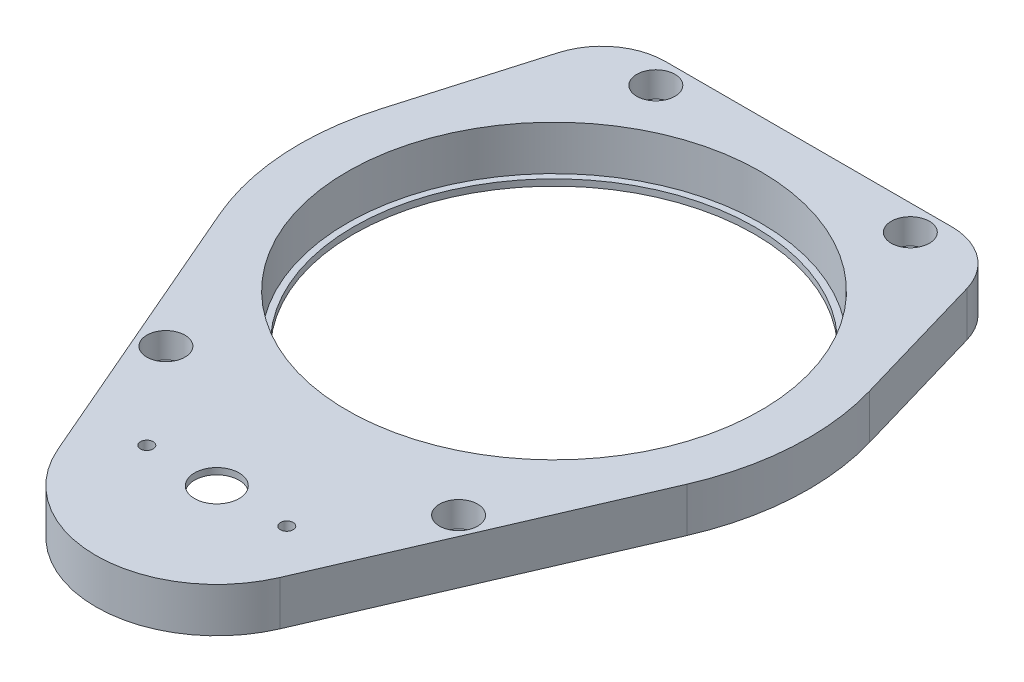
from build123d import *

# Parameters (mm, degrees)
SKETCH1_R           = 32.5
BOSS_EXTRUDE1_DEPTH = 7
SKETCH2_R           = 3.5
SKETCH2_R_2         = 1
CUT_EXTRUDE1_DEPTH  = 10
SKETCH3_R           = 35.5
CUT_EXTRUDE2_DEPTH  = 6
FILLET1_R           = 10
SKETCH4_R           = 1.5
CUT_EXTRUDE3_DEPTH  = 10
SKETCH5_R           = 3.5
SKETCH5_R_2         = 1.5
BOSS_EXTRUDE2_DEPTH = 6
SKETCH6_R           = 3
CUT_EXTRUDE4_DEPTH  = 4
SKETCH8_R           = 3
SKETCH8_R_2         = 1
BOSS_EXTRUDE3_DEPTH = 3
SKETCH9_R           = 35.5
SKETCH9_R_2         = 31.5
BOSS_EXTRUDE4_DEPTH = 1


with BuildPart() as part:
    # Sketch1 → Boss-Extrude1 (new body)
    with BuildSketch(Plane.XZ.offset(-37.073034342)):
        with BuildLine():
            ThreePointArc((38.4, -11.2), (39.923628268, 2.470608411), (36.72611339, 15.849056604))
            Line((36.72611339, 15.849056604), (17.44490386, 60.528301887))
            ThreePointArc((17.44490386, 60.528301887), (0, 72), (-17.44490386, 60.528301887))
            Line((-17.44490386, 60.528301887), (-36.72611339, 15.849056604))
            ThreePointArc((-36.72611339, 15.849056604), (-39.923628268, 2.470608411), (-38.4, -11.2))
            Line((-38.4, -11.2), (-30, -40))
            Line((-30, -40), (30, -40))
            Line((30, -40), (38.4, -11.2))
        make_face()
        Circle(SKETCH1_R, mode=Mode.SUBTRACT)
    extrude(amount=-BOSS_EXTRUDE1_DEPTH)

    # Sketch2 → Cut-Extrude1 (cut)
    with BuildSketch(Plane(origin=(0, 44.073034342, 0), x_dir=(1, 0, 0), z_dir=(0, 1, 0))):
        with Locations((0, -53)):
            Circle(SKETCH2_R)
        with Locations((11, -53)):
            Circle(SKETCH2_R_2)
        with Locations((-11, -53)):
            Circle(SKETCH2_R_2)
    extrude(amount=-CUT_EXTRUDE1_DEPTH, mode=Mode.SUBTRACT)

    # Sketch3 → Cut-Extrude2 (cut)
    with BuildSketch(Plane.XZ.offset(-37.073034342)):
        with BuildLine():
            Line((34.889807721, 15.056603774), (15.608598191, 59.735849057))
            ThreePointArc((15.608598191, 59.735849057), (0, 70), (-15.608598191, 59.735849057))
            Line((-15.608598191, 59.735849057), (-34.889807721, 15.056603774))
            ThreePointArc((-34.889807721, 15.056603774), (-37.927446855, 2.347077991), (-36.48, -10.64))
            Line((-36.48, -10.64), (-28.5, -38))
            Line((-28.5, -38), (28.5, -38))
            Line((28.5, -38), (36.48, -10.64))
            ThreePointArc((36.48, -10.64), (37.927446855, 2.347077991), (34.889807721, 15.056603774))
        make_face()
        Circle(SKETCH3_R, mode=Mode.SUBTRACT)
    extrude(amount=-CUT_EXTRUDE2_DEPTH, mode=Mode.SUBTRACT)

    # Fillet1
    fillet1_edges = [part.edges().sort_by_distance(p)[0] for p in [
        (30, 40.573034342, -40),
        (-30, 40.573034342, -40),
        (28.5, 40.073034342, -38),
        (-28.5, 40.073034342, -38),
    ]]
    fillet(fillet1_edges, radius=FILLET1_R)

    # Sketch4 → Cut-Extrude3 (cut)
    with BuildSketch(Plane(origin=(0, 44.073034342, 0), x_dir=(1, 0, 0), z_dir=(0, 1, 0))):
        with Locations((-20, 36)):
            Circle(SKETCH4_R)
        with Locations((20, 36)):
            Circle(SKETCH4_R)
        with Locations((23, -38)):
            Circle(SKETCH4_R)
        with Locations((-23, -38)):
            Circle(SKETCH4_R)
    extrude(amount=-CUT_EXTRUDE3_DEPTH, mode=Mode.SUBTRACT)

    # Sketch5 → Boss-Extrude2 (add)
    with BuildSketch(Plane.XZ.offset(-43.073034342)):
        with Locations((-23, 38)):
            Circle(SKETCH5_R)
        with Locations((-23, 38)):
            Circle(SKETCH5_R_2, mode=Mode.SUBTRACT)
        with Locations((23, 38)):
            Circle(SKETCH5_R)
        with Locations((23, 38)):
            Circle(SKETCH5_R_2, mode=Mode.SUBTRACT)
        with Locations((-20, -36)):
            Circle(SKETCH5_R)
        with Locations((-20, -36)):
            Circle(SKETCH5_R_2, mode=Mode.SUBTRACT)
        with Locations((20, -36)):
            Circle(SKETCH5_R)
        with Locations((20, -36)):
            Circle(SKETCH5_R_2, mode=Mode.SUBTRACT)
    extrude(amount=BOSS_EXTRUDE2_DEPTH)

    # Sketch6 → Cut-Extrude4 (cut)
    with BuildSketch(Plane(origin=(0, 44.073034342, 0), x_dir=(1, 0, 0), z_dir=(0, 1, 0))):
        with Locations((-20, 36)):
            Circle(SKETCH6_R)
        with Locations((20, 36)):
            Circle(SKETCH6_R)
        with Locations((-23, -38)):
            Circle(SKETCH6_R)
        with Locations((23, -38)):
            Circle(SKETCH6_R)
    extrude(amount=-CUT_EXTRUDE4_DEPTH, mode=Mode.SUBTRACT)

    # Sketch8 → Boss-Extrude3 (add)
    with BuildSketch(Plane.XZ.offset(-43.073034342)):
        with Locations((11, 53)):
            Circle(SKETCH8_R)
        with Locations((11, 53)):
            Circle(SKETCH8_R_2, mode=Mode.SUBTRACT)
        with Locations((-11, 53)):
            Circle(SKETCH8_R)
        with Locations((-11, 53)):
            Circle(SKETCH8_R_2, mode=Mode.SUBTRACT)
    extrude(amount=BOSS_EXTRUDE3_DEPTH)

    # Sketch9 → Boss-Extrude4 (add)
    with BuildSketch(Plane.XZ.offset(-37.073034342)):
        Circle(SKETCH9_R)
        Circle(SKETCH9_R_2, mode=Mode.SUBTRACT)
    extrude(amount=BOSS_EXTRUDE4_DEPTH)


solid = part.part
